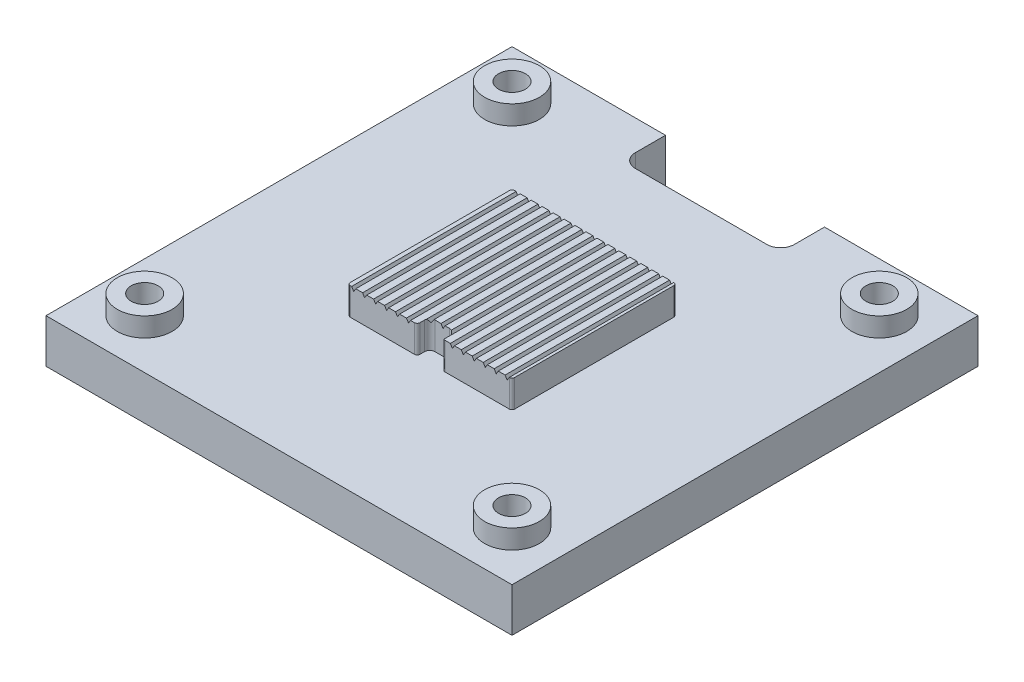
from build123d import *

# Parameters (mm, degrees)
SKETCH1_W           = 85
SKETCH1_H           = 85
SKETCH1_R           = 2.4575
BOSS_EXTRUDE1_DEPTH = 8
SKETCH2_R           = 3.969
CUT_EXTRUDE1_DEPTH  = 4.166
SKETCH3_R           = 5
SKETCH3_R_2         = 2.4575
BOSS_EXTRUDE2_DEPTH = 3.5
BOSS_EXTRUDE3_DEPTH = 5
SKETCH5_W           = 29
SKETCH5_H           = 8
CUT_EXTRUDE2_DEPTH  = 10
FILLET1_R           = 2.5
CUT_EXTRUDE3_REACH  = 59.5


with BuildPart() as part:
    # Sketch1 → Boss-Extrude1 (new body)
    with BuildSketch(Plane(origin=(0, 0, 0), x_dir=(1, 0, 0), z_dir=(0, 1, 0))):
        Rectangle(SKETCH1_W, SKETCH1_H)
        with Locations((-33.5, 33.5)):
            Circle(SKETCH1_R, mode=Mode.SUBTRACT)
        with Locations((-33.5, -33.5)):
            Circle(SKETCH1_R, mode=Mode.SUBTRACT)
        with Locations((33.5, -33.5)):
            Circle(SKETCH1_R, mode=Mode.SUBTRACT)
        with Locations((33.5, 33.5)):
            Circle(SKETCH1_R, mode=Mode.SUBTRACT)
    extrude(amount=BOSS_EXTRUDE1_DEPTH)

    # Sketch2 → Cut-Extrude1 (cut)
    with BuildSketch(Plane.XZ):
        with Locations((-33.5, 33.5)):
            Circle(SKETCH2_R)
        with Locations((33.5, 33.5)):
            Circle(SKETCH2_R)
        with Locations((33.5, -33.5)):
            Circle(SKETCH2_R)
        with Locations((-33.5, -33.5)):
            Circle(SKETCH2_R)
    extrude(amount=-CUT_EXTRUDE1_DEPTH, mode=Mode.SUBTRACT)

    # Sketch3 → Boss-Extrude2 (add)
    with BuildSketch(Plane(origin=(0, 8, 0), x_dir=(1, 0, 0), z_dir=(0, 1, 0))):
        with Locations((33.5, -33.5)):
            Circle(SKETCH3_R)
        with Locations((33.5, -33.5)):
            Circle(SKETCH3_R_2, mode=Mode.SUBTRACT)
        with Locations((-33.5, -33.5)):
            Circle(SKETCH3_R)
        with Locations((-33.5, -33.5)):
            Circle(SKETCH3_R_2, mode=Mode.SUBTRACT)
        with Locations((-33.5, 33.5)):
            Circle(SKETCH3_R)
        with Locations((-33.5, 33.5)):
            Circle(SKETCH3_R_2, mode=Mode.SUBTRACT)
        with Locations((33.5, 33.5)):
            Circle(SKETCH3_R)
        with Locations((33.5, 33.5)):
            Circle(SKETCH3_R_2, mode=Mode.SUBTRACT)
    extrude(amount=BOSS_EXTRUDE2_DEPTH)

    # Sketch4 → Boss-Extrude3 (add)
    with BuildSketch(Plane(origin=(0, 8, 0), x_dir=(1, 0, 0), z_dir=(0, 1, 0))):
        with BuildLine():
            Line((2.2929, -14.5), (2.2929, -13.7071))
            ThreePointArc((2.2929, -13.7071), (2.000006781, -12.999993219), (1.2929, -12.7071))
            Line((1.2929, -12.7071), (-1.2929, -12.7071))
            ThreePointArc((-1.2929, -12.7071), (-2.000006781, -12.999993219), (-2.2929, -13.7071))
            Line((-2.2929, -13.7071), (-2.2929, -14.5))
            ThreePointArc((-2.2929, -14.5), (-2.439346609, -14.853553391), (-2.7929, -15))
            Line((-2.7929, -15), (-14.5, -15))
            ThreePointArc((-14.5, -15), (-14.853553391, -14.853553391), (-15, -14.5))
            Line((-15, -14.5), (-15, 14.5))
            ThreePointArc((-15, 14.5), (-14.853553391, 14.853553391), (-14.5, 15))
            Line((-14.5, 15), (14.5, 15))
            ThreePointArc((14.5, 15), (14.853553391, 14.853553391), (15, 14.5))
            Line((15, 14.5), (15, -14.5))
            ThreePointArc((15, -14.5), (14.853553391, -14.853553391), (14.5, -15))
            Line((14.5, -15), (2.7929, -15))
            ThreePointArc((2.7929, -15), (2.439346609, -14.853553391), (2.2929, -14.5))
        make_face()
    extrude(amount=BOSS_EXTRUDE3_DEPTH)

    # Sketch5 → Cut-Extrude2 (cut)
    with BuildSketch(Plane(origin=(0, 8, 0), x_dir=(1, 0, 0), z_dir=(0, 1, 0))):
        with Locations((0, 38.5)):
            Rectangle(SKETCH5_W, SKETCH5_H)
    extrude(amount=-CUT_EXTRUDE2_DEPTH, mode=Mode.SUBTRACT)

    # Fillet1
    fillet1_edges = [part.edges().sort_by_distance(p)[0] for p in [
        (14.5, 4, -34.5),
        (-14.5, 4, -34.5),
    ]]
    fillet(fillet1_edges, radius=FILLET1_R)

    # Sketch7 → Cut-Extrude3 (cut, up to next)
    with BuildSketch(Plane(origin=(0, 0, -15), x_dir=(-1, 0, 0), z_dir=(0, 0, -1)), mode=Mode.PRIVATE) as cut_extrude3_sk1:
        Polygon((-14.5, 13), (-14.125, 12.38), (-13.75, 13), align=None)
    cut_extrude3_tool1 = extrude(cut_extrude3_sk1.sketch, amount=-CUT_EXTRUDE3_REACH, mode=Mode.PRIVATE) & part.part
    add(cut_extrude3_tool1.solids().sort_by_distance((14.125, 12.793333, -15))[0], mode=Mode.SUBTRACT)
    # Sketch7 → Cut-Extrude3 (cut, up to next)
    with BuildSketch(Plane(origin=(0, 0, -15), x_dir=(-1, 0, 0), z_dir=(0, 0, -1)), mode=Mode.PRIVATE) as cut_extrude3_sk2:
        Polygon((-12.5, 13), (-12.125, 12.38), (-11.75, 13), align=None)
    cut_extrude3_tool2 = extrude(cut_extrude3_sk2.sketch, amount=-CUT_EXTRUDE3_REACH, mode=Mode.PRIVATE) & part.part
    add(cut_extrude3_tool2.solids().sort_by_distance((12.125, 12.793333, -15))[0], mode=Mode.SUBTRACT)
    # Sketch7 → Cut-Extrude3 (cut, up to next)
    with BuildSketch(Plane(origin=(0, 0, -15), x_dir=(-1, 0, 0), z_dir=(0, 0, -1)), mode=Mode.PRIVATE) as cut_extrude3_sk3:
        Polygon((-10.5, 13), (-10.125, 12.38), (-9.75, 13), align=None)
    cut_extrude3_tool3 = extrude(cut_extrude3_sk3.sketch, amount=-CUT_EXTRUDE3_REACH, mode=Mode.PRIVATE) & part.part
    add(cut_extrude3_tool3.solids().sort_by_distance((10.125, 12.793333, -15))[0], mode=Mode.SUBTRACT)
    # Sketch7 → Cut-Extrude3 (cut, up to next)
    with BuildSketch(Plane(origin=(0, 0, -15), x_dir=(-1, 0, 0), z_dir=(0, 0, -1)), mode=Mode.PRIVATE) as cut_extrude3_sk4:
        Polygon((-8.5, 13), (-8.125, 12.38), (-7.75, 13), align=None)
    cut_extrude3_tool4 = extrude(cut_extrude3_sk4.sketch, amount=-CUT_EXTRUDE3_REACH, mode=Mode.PRIVATE) & part.part
    add(cut_extrude3_tool4.solids().sort_by_distance((8.125, 12.793333, -15))[0], mode=Mode.SUBTRACT)
    # Sketch7 → Cut-Extrude3 (cut, up to next)
    with BuildSketch(Plane(origin=(0, 0, -15), x_dir=(-1, 0, 0), z_dir=(0, 0, -1)), mode=Mode.PRIVATE) as cut_extrude3_sk5:
        Polygon((-6.5, 13), (-6.125, 12.38), (-5.75, 13), align=None)
    cut_extrude3_tool5 = extrude(cut_extrude3_sk5.sketch, amount=-CUT_EXTRUDE3_REACH, mode=Mode.PRIVATE) & part.part
    add(cut_extrude3_tool5.solids().sort_by_distance((6.125, 12.793333, -15))[0], mode=Mode.SUBTRACT)
    # Sketch7 → Cut-Extrude3 (cut, up to next)
    with BuildSketch(Plane(origin=(0, 0, -15), x_dir=(-1, 0, 0), z_dir=(0, 0, -1)), mode=Mode.PRIVATE) as cut_extrude3_sk6:
        Polygon((-4.5, 13), (-4.125, 12.38), (-3.75, 13), align=None)
    cut_extrude3_tool6 = extrude(cut_extrude3_sk6.sketch, amount=-CUT_EXTRUDE3_REACH, mode=Mode.PRIVATE) & part.part
    add(cut_extrude3_tool6.solids().sort_by_distance((4.125, 12.793333, -15))[0], mode=Mode.SUBTRACT)
    # Sketch7 → Cut-Extrude3 (cut, up to next)
    with BuildSketch(Plane(origin=(0, 0, -15), x_dir=(-1, 0, 0), z_dir=(0, 0, -1)), mode=Mode.PRIVATE) as cut_extrude3_sk7:
        Polygon((-2.5, 13), (-2.125, 12.38), (-1.75, 13), align=None)
    cut_extrude3_tool7 = extrude(cut_extrude3_sk7.sketch, amount=-CUT_EXTRUDE3_REACH, mode=Mode.PRIVATE) & part.part
    add(cut_extrude3_tool7.solids().sort_by_distance((2.125, 12.793333, -15))[0], mode=Mode.SUBTRACT)
    # Sketch7 → Cut-Extrude3 (cut, up to next)
    with BuildSketch(Plane(origin=(0, 0, -15), x_dir=(-1, 0, 0), z_dir=(0, 0, -1)), mode=Mode.PRIVATE) as cut_extrude3_sk8:
        Polygon((-0.5, 13), (-0.125, 12.38), (0.25, 13), align=None)
    cut_extrude3_tool8 = extrude(cut_extrude3_sk8.sketch, amount=-CUT_EXTRUDE3_REACH, mode=Mode.PRIVATE) & part.part
    add(cut_extrude3_tool8.solids().sort_by_distance((0.125, 12.793333, -15))[0], mode=Mode.SUBTRACT)
    # Sketch7 → Cut-Extrude3 (cut, up to next)
    with BuildSketch(Plane(origin=(0, 0, -15), x_dir=(-1, 0, 0), z_dir=(0, 0, -1)), mode=Mode.PRIVATE) as cut_extrude3_sk9:
        Polygon((1.5, 13), (1.875, 12.38), (2.25, 13), align=None)
    cut_extrude3_tool9 = extrude(cut_extrude3_sk9.sketch, amount=-CUT_EXTRUDE3_REACH, mode=Mode.PRIVATE) & part.part
    add(cut_extrude3_tool9.solids().sort_by_distance((-1.875, 12.793333, -15))[0], mode=Mode.SUBTRACT)
    # Sketch7 → Cut-Extrude3 (cut, up to next)
    with BuildSketch(Plane(origin=(0, 0, -15), x_dir=(-1, 0, 0), z_dir=(0, 0, -1)), mode=Mode.PRIVATE) as cut_extrude3_sk10:
        Polygon((3.5, 13), (3.875, 12.38), (4.25, 13), align=None)
    cut_extrude3_tool10 = extrude(cut_extrude3_sk10.sketch, amount=-CUT_EXTRUDE3_REACH, mode=Mode.PRIVATE) & part.part
    add(cut_extrude3_tool10.solids().sort_by_distance((-3.875, 12.793333, -15))[0], mode=Mode.SUBTRACT)
    # Sketch7 → Cut-Extrude3 (cut, up to next)
    with BuildSketch(Plane(origin=(0, 0, -15), x_dir=(-1, 0, 0), z_dir=(0, 0, -1)), mode=Mode.PRIVATE) as cut_extrude3_sk11:
        Polygon((5.5, 13), (5.875, 12.38), (6.25, 13), align=None)
    cut_extrude3_tool11 = extrude(cut_extrude3_sk11.sketch, amount=-CUT_EXTRUDE3_REACH, mode=Mode.PRIVATE) & part.part
    add(cut_extrude3_tool11.solids().sort_by_distance((-5.875, 12.793333, -15))[0], mode=Mode.SUBTRACT)
    # Sketch7 → Cut-Extrude3 (cut, up to next)
    with BuildSketch(Plane(origin=(0, 0, -15), x_dir=(-1, 0, 0), z_dir=(0, 0, -1)), mode=Mode.PRIVATE) as cut_extrude3_sk12:
        Polygon((7.5, 13), (7.875, 12.38), (8.25, 13), align=None)
    cut_extrude3_tool12 = extrude(cut_extrude3_sk12.sketch, amount=-CUT_EXTRUDE3_REACH, mode=Mode.PRIVATE) & part.part
    add(cut_extrude3_tool12.solids().sort_by_distance((-7.875, 12.793333, -15))[0], mode=Mode.SUBTRACT)
    # Sketch7 → Cut-Extrude3 (cut, up to next)
    with BuildSketch(Plane(origin=(0, 0, -15), x_dir=(-1, 0, 0), z_dir=(0, 0, -1)), mode=Mode.PRIVATE) as cut_extrude3_sk13:
        Polygon((9.5, 13), (9.875, 12.38), (10.25, 13), align=None)
    cut_extrude3_tool13 = extrude(cut_extrude3_sk13.sketch, amount=-CUT_EXTRUDE3_REACH, mode=Mode.PRIVATE) & part.part
    add(cut_extrude3_tool13.solids().sort_by_distance((-9.875, 12.793333, -15))[0], mode=Mode.SUBTRACT)
    # Sketch7 → Cut-Extrude3 (cut, up to next)
    with BuildSketch(Plane(origin=(0, 0, -15), x_dir=(-1, 0, 0), z_dir=(0, 0, -1)), mode=Mode.PRIVATE) as cut_extrude3_sk14:
        Polygon((11.5, 13), (11.875, 12.38), (12.25, 13), align=None)
    cut_extrude3_tool14 = extrude(cut_extrude3_sk14.sketch, amount=-CUT_EXTRUDE3_REACH, mode=Mode.PRIVATE) & part.part
    add(cut_extrude3_tool14.solids().sort_by_distance((-11.875, 12.793333, -15))[0], mode=Mode.SUBTRACT)
    # Sketch7 → Cut-Extrude3 (cut, up to next)
    with BuildSketch(Plane(origin=(0, 0, -15), x_dir=(-1, 0, 0), z_dir=(0, 0, -1)), mode=Mode.PRIVATE) as cut_extrude3_sk15:
        Polygon((13.5, 13), (13.875, 12.38), (14.25, 13), align=None)
    cut_extrude3_tool15 = extrude(cut_extrude3_sk15.sketch, amount=-CUT_EXTRUDE3_REACH, mode=Mode.PRIVATE) & part.part
    add(cut_extrude3_tool15.solids().sort_by_distance((-13.875, 12.793333, -15))[0], mode=Mode.SUBTRACT)


solid = part.part
